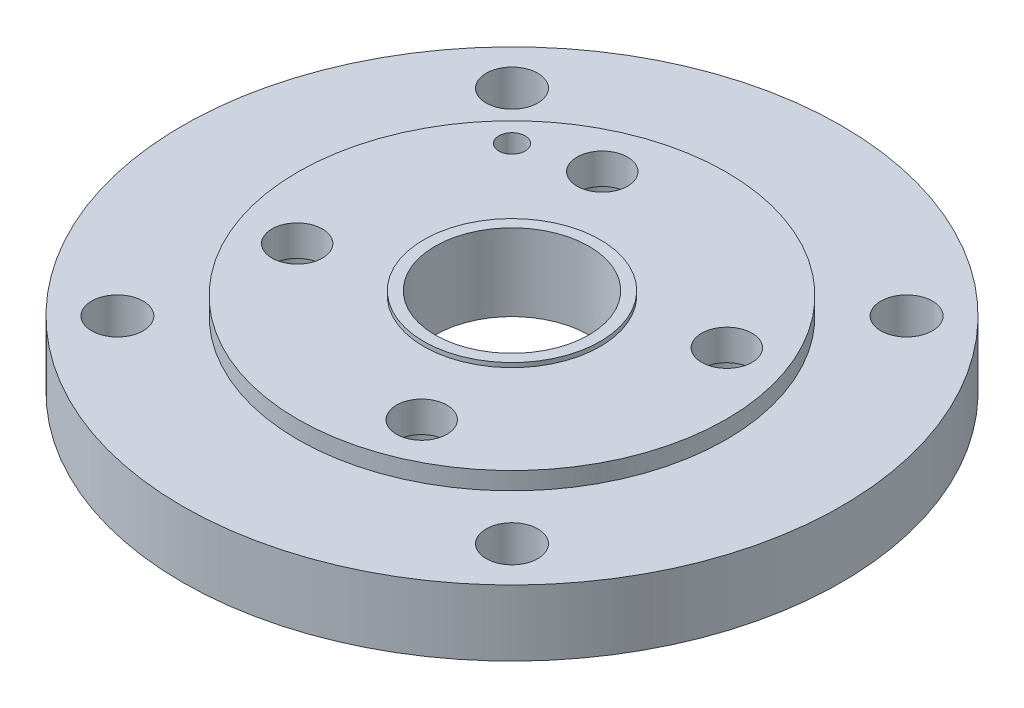
from build123d import *

# Parameters (mm, degrees)
SKETCH1_R               = 150
SKETCH1_R_2             = 97.5
SKETCH1_R_3             = 11.75
BOSS_EXTRUDE1_DEPTH     = 30
SKETCH1_3_R             = 97.5
SKETCH1_3_R_2           = 40.15
SKETCH1_3_R_3           = 17.5
SKETCH1_3_R_4           = 6
BOSS_EXTRUDE2_DEPTH     = 38
SKETCH1_4_R             = 40.15
SKETCH1_4_R_2           = 35
BOSS_EXTRUDE3_DEPTH     = 40
BOSS_EXTRUDE4_START     = 38
SKETCH1_5_R             = 17.5
SKETCH1_5_R_2           = 11.5
BOSS_EXTRUDE4_DEPTH     = 14
SKETCH2_R               = 43.5
CUT_EXTRUDE1_DEPTH      = 1
CUT_EXTRUDE1_DEPTH_BACK = 5


with BuildPart() as part:
    # Sketch1 → Boss-Extrude1 (new body)
    with BuildSketch(Plane(origin=(0, 0, 0), x_dir=(1, 0, 0), z_dir=(0, 1, 0))):
        Circle(SKETCH1_R)
        Circle(SKETCH1_R_2, mode=Mode.SUBTRACT)
        with Locations((-89.802561211, -89.802561211)):
            Circle(SKETCH1_R_3, mode=Mode.SUBTRACT)
        with Locations((89.802561211, -89.802561211)):
            Circle(SKETCH1_R_3, mode=Mode.SUBTRACT)
        with Locations((89.802561211, 89.802561211)):
            Circle(SKETCH1_R_3, mode=Mode.SUBTRACT)
        with Locations((-89.802561211, 89.802561211)):
            Circle(SKETCH1_R_3, mode=Mode.SUBTRACT)
    extrude(amount=BOSS_EXTRUDE1_DEPTH)

    # Sketch1_3 → Boss-Extrude2 (add)
    with BuildSketch(Plane(origin=(0, 0, 0), x_dir=(1, 0, 0), z_dir=(0, 1, 0))):
        Circle(SKETCH1_3_R)
        Circle(SKETCH1_3_R_2, mode=Mode.SUBTRACT)
        with Locations((-28.338059011, 69.440293861)):
            Circle(SKETCH1_3_R_3, mode=Mode.SUBTRACT)
        with Locations((-69.440293861, -28.338059011)):
            Circle(SKETCH1_3_R_3, mode=Mode.SUBTRACT)
        with Locations((28.338059011, -69.440293861)):
            Circle(SKETCH1_3_R_3, mode=Mode.SUBTRACT)
        with Locations((69.440293861, 28.338059011)):
            Circle(SKETCH1_3_R_3, mode=Mode.SUBTRACT)
        with Locations((-60, 60)):
            Circle(SKETCH1_3_R_4, mode=Mode.SUBTRACT)
    extrude(amount=BOSS_EXTRUDE2_DEPTH)

    # Sketch1_4 → Boss-Extrude3 (add)
    with BuildSketch(Plane(origin=(0, 0, 0), x_dir=(1, 0, 0), z_dir=(0, 1, 0))):
        Circle(SKETCH1_4_R)
        Circle(SKETCH1_4_R_2, mode=Mode.SUBTRACT)
    extrude(amount=BOSS_EXTRUDE3_DEPTH)

    # Sketch1_5 → Boss-Extrude4 (add)
    with BuildSketch(Plane(origin=(0, 0, 0), x_dir=(1, 0, 0), z_dir=(0, 1, 0)).offset(BOSS_EXTRUDE4_START)):
        with Locations((-28.338059011, 69.440293861)):
            Circle(SKETCH1_5_R)
        with Locations((-28.338059011, 69.440293861)):
            Circle(SKETCH1_5_R_2, mode=Mode.SUBTRACT)
        with Locations((69.440293861, 28.338059011)):
            Circle(SKETCH1_5_R)
        with Locations((69.440293861, 28.338059011)):
            Circle(SKETCH1_5_R_2, mode=Mode.SUBTRACT)
        with Locations((28.338059011, -69.440293861)):
            Circle(SKETCH1_5_R)
        with Locations((28.338059011, -69.440293861)):
            Circle(SKETCH1_5_R_2, mode=Mode.SUBTRACT)
        with Locations((-69.440293861, -28.338059011)):
            Circle(SKETCH1_5_R)
        with Locations((-69.440293861, -28.338059011)):
            Circle(SKETCH1_5_R_2, mode=Mode.SUBTRACT)
    extrude(amount=-BOSS_EXTRUDE4_DEPTH)

    # Sketch2 → Cut-Extrude1 (cut, two sides)
    with BuildSketch(Plane.XZ) as cut_extrude1_sk:
        Circle(SKETCH2_R)
    extrude(amount=CUT_EXTRUDE1_DEPTH, mode=Mode.SUBTRACT)
    extrude(cut_extrude1_sk.sketch, amount=-CUT_EXTRUDE1_DEPTH_BACK, mode=Mode.SUBTRACT)


solid = part.part
